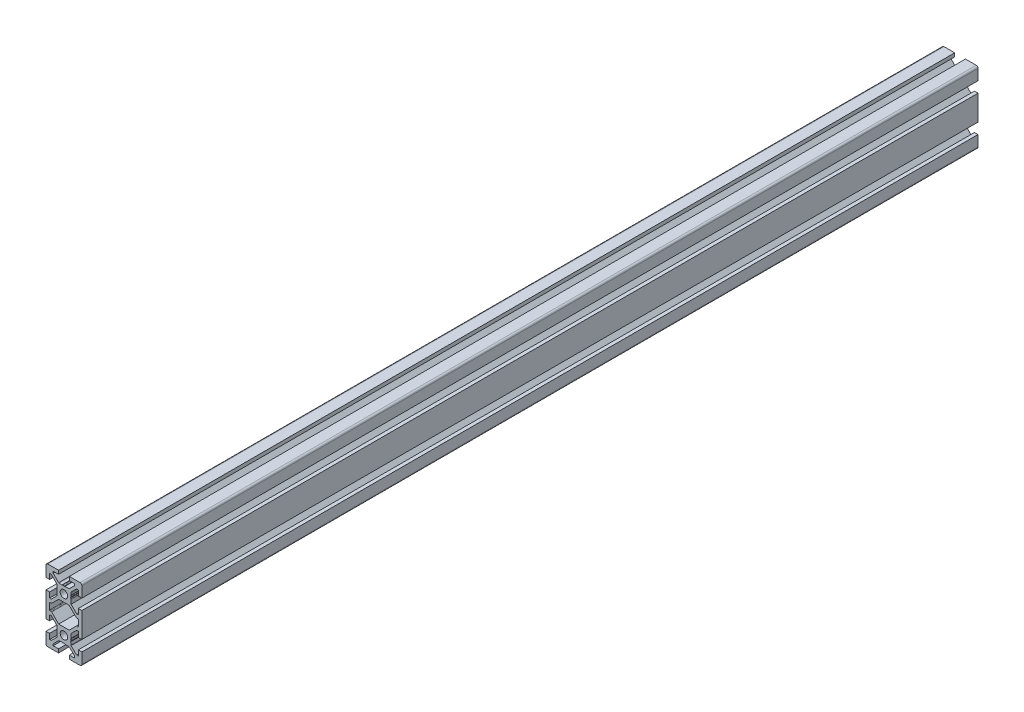
from build123d import *

# Parameters (mm, degrees)
SKETCH1_R           = 2.1
BOSS_EXTRUDE1_DEPTH = 500


with BuildPart() as part:
    # Sketch1 → Boss-Extrude1 (new body)
    with BuildSketch(Plane(origin=(0, 0, -600), x_dir=(-1, 0, 0), z_dir=(0, 0, -1))):
        with BuildLine():
            Line((10, -7), (10, 7))
            Line((10, 7), (8, 7))
            Line((8, 7), (8, 4))
            Line((8, 4), (7.060660172, 4))
            Line((7.060660172, 4), (4, 7.060660172))
            Line((4, 7.060660172), (4, 7.5))
            Line((4, 7.5), (3.750976592, 8.781114371))
            Line((3.750976592, 8.781114371), (3.933012702, 9.096410162))
            ThreePointArc((3.933012702, 9.096410162), (4, 9.346410162), (3.933012702, 9.596410162))
            Line((3.933012702, 9.596410162), (3.7, 10))
            Line((3.7, 10), (3.933012702, 10.403589838))
            ThreePointArc((3.933012702, 10.403589838), (3.982962913, 10.524180316), (4, 10.653589838))
            Line((4, 10.653589838), (4, 12.939339828))
            Line((4, 12.939339828), (7.060660172, 16))
            Line((7.060660172, 16), (8, 16))
            Line((8, 16), (8, 13))
            Line((8, 13), (10, 13))
            Line((10, 13), (10, 19))
            ThreePointArc((10, 19), (9.707106781, 19.707106781), (9, 20))
            Line((9, 20), (3, 20))
            Line((3, 20), (3, 18))
            Line((3, 18), (6, 18))
            Line((6, 18), (6, 17.060660172))
            Line((6, 17.060660172), (2.939339828, 14))
            Line((2.939339828, 14), (2.5, 14))
            Line((2.5, 14), (1.218885629, 13.750976592))
            Line((1.218885629, 13.750976592), (0.903589838, 13.933012702))
            ThreePointArc((0.903589838, 13.933012702), (0.653589838, 14), (0.403589838, 13.933012702))
            Line((0.403589838, 13.933012702), (0, 13.7))
            Line((0, 13.7), (-0.403589838, 13.933012702))
            ThreePointArc((-0.403589838, 13.933012702), (-0.524180316, 13.982962913), (-0.653589838, 14))
            Line((-0.653589838, 14), (-2.939339828, 14))
            Line((-2.939339828, 14), (-6, 17.060660172))
            Line((-6, 17.060660172), (-6, 18))
            Line((-6, 18), (-3, 18))
            Line((-3, 18), (-3, 20))
            Line((-3, 20), (-9, 20))
            ThreePointArc((-9, 20), (-9.707106781, 19.707106781), (-10, 19))
            Line((-10, 19), (-10, 13))
            Line((-10, 13), (-8, 13))
            Line((-8, 13), (-8, 16))
            Line((-8, 16), (-7.060660172, 16))
            Line((-7.060660172, 16), (-4, 12.939339828))
            Line((-4, 12.939339828), (-4, 12.5))
            Line((-4, 12.5), (-3.750976592, 11.218885629))
            Line((-3.750976592, 11.218885629), (-3.933012702, 10.903589838))
            ThreePointArc((-3.933012702, 10.903589838), (-4, 10.653589838), (-3.933012702, 10.403589838))
            Line((-3.933012702, 10.403589838), (-3.7, 10))
            Line((-3.7, 10), (-3.933012702, 9.596410162))
            ThreePointArc((-3.933012702, 9.596410162), (-3.982962913, 9.475819684), (-4, 9.346410162))
            Line((-4, 9.346410162), (-4, 7.060660172))
            Line((-4, 7.060660172), (-7.060660172, 4))
            Line((-7.060660172, 4), (-8, 4))
            Line((-8, 4), (-8, 7))
            Line((-8, 7), (-10, 7))
            Line((-10, 7), (-10, -7))
            Line((-10, -7), (-8, -7))
            Line((-8, -7), (-8, -4))
            Line((-8, -4), (-7.060660172, -4))
            Line((-7.060660172, -4), (-4, -7.060660172))
            Line((-4, -7.060660172), (-4, -9.346410162))
            ThreePointArc((-4, -9.346410162), (-3.982962913, -9.475819684), (-3.933012702, -9.596410162))
            Line((-3.933012702, -9.596410162), (-3.7, -10))
            Line((-3.7, -10), (-3.933012702, -10.403589838))
            ThreePointArc((-3.933012702, -10.403589838), (-4, -10.653589838), (-3.933012702, -10.903589838))
            Line((-3.933012702, -10.903589838), (-3.750976592, -11.218885629))
            Line((-3.750976592, -11.218885629), (-4, -12.5))
            Line((-4, -12.5), (-4, -12.939339828))
            Line((-4, -12.939339828), (-7.060660172, -16))
            Line((-7.060660172, -16), (-8, -16))
            Line((-8, -16), (-8, -13))
            Line((-8, -13), (-10, -13))
            Line((-10, -13), (-10, -19))
            ThreePointArc((-10, -19), (-9.707106781, -19.707106781), (-9, -20))
            Line((-9, -20), (-3, -20))
            Line((-3, -20), (-3, -18))
            Line((-3, -18), (-6, -18))
            Line((-6, -18), (-6, -17.060660172))
            Line((-6, -17.060660172), (-2.939339828, -14))
            Line((-2.939339828, -14), (-0.653589838, -14))
            ThreePointArc((-0.653589838, -14), (-0.524180316, -13.982962913), (-0.403589838, -13.933012702))
            Line((-0.403589838, -13.933012702), (0, -13.7))
            Line((0, -13.7), (0.403589839, -13.933012702))
            ThreePointArc((0.403589839, -13.933012702), (0.653589839, -14), (0.903589838, -13.933012702))
            Line((0.903589838, -13.933012702), (1.218885629, -13.750976592))
            Line((1.218885629, -13.750976592), (2.5, -14))
            Line((2.5, -14), (2.939339828, -14))
            Line((2.939339828, -14), (6, -17.060660172))
            Line((6, -17.060660172), (6, -18))
            Line((6, -18), (3, -18))
            Line((3, -18), (3, -20))
            Line((3, -20), (9, -20))
            ThreePointArc((9, -20), (9.707106781, -19.707106781), (10, -19))
            Line((10, -19), (10, -13))
            Line((10, -13), (8, -13))
            Line((8, -13), (8, -16))
            Line((8, -16), (7.060660172, -16))
            Line((7.060660172, -16), (4, -12.939339828))
            Line((4, -12.939339828), (4, -10.653589838))
            ThreePointArc((4, -10.653589838), (3.982962913, -10.524180316), (3.933012702, -10.403589838))
            Line((3.933012702, -10.403589838), (3.7, -10))
            Line((3.7, -10), (3.933012702, -9.596410162))
            ThreePointArc((3.933012702, -9.596410162), (4, -9.346410162), (3.933012702, -9.096410162))
            Line((3.933012702, -9.096410162), (3.750976592, -8.781114371))
            Line((3.750976592, -8.781114371), (4, -7.5))
            Line((4, -7.5), (4, -7.060660172))
            Line((4, -7.060660172), (7.060660172, -4))
            Line((7.060660172, -4), (8, -4))
            Line((8, -4), (8, -7))
            Line((8, -7), (10, -7))
        make_face()
        with Locations((0, -10)):
            Circle(SKETCH1_R, mode=Mode.SUBTRACT)
        with Locations((0, 10)):
            Circle(SKETCH1_R, mode=Mode.SUBTRACT)
        with BuildLine():
            Line((8, 1.7), (8, -1.7))
            ThreePointArc((8, -1.7), (7.912132034, -1.912132034), (7.7, -2))
            Line((7.7, -2), (7.063603897, -2))
            ThreePointArc((7.063603897, -2), (6.948798867, -2.02283614), (6.851471863, -2.087867966))
            Line((6.851471863, -2.087867966), (2.939339828, -6))
            Line((2.939339828, -6), (-2.939339828, -6))
            Line((-2.939339828, -6), (-6.851471863, -2.087867966))
            ThreePointArc((-6.851471863, -2.087867966), (-6.948798867, -2.02283614), (-7.063603897, -2))
            Line((-7.063603897, -2), (-7.7, -2))
            ThreePointArc((-7.7, -2), (-7.912132034, -1.912132034), (-8, -1.7))
            Line((-8, -1.7), (-8, 1.7))
            ThreePointArc((-8, 1.7), (-7.912132034, 1.912132034), (-7.7, 2))
            Line((-7.7, 2), (-7.063603897, 2))
            ThreePointArc((-7.063603897, 2), (-6.948798867, 2.02283614), (-6.851471863, 2.087867966))
            Line((-6.851471863, 2.087867966), (-2.939339828, 6))
            Line((-2.939339828, 6), (2.939339828, 6))
            Line((2.939339828, 6), (6.851471863, 2.087867966))
            ThreePointArc((6.851471863, 2.087867966), (6.948798867, 2.02283614), (7.063603897, 2))
            Line((7.063603897, 2), (7.7, 2))
            ThreePointArc((7.7, 2), (7.912132034, 1.912132034), (8, 1.7))
        make_face(mode=Mode.SUBTRACT)
    extrude(amount=-BOSS_EXTRUDE1_DEPTH)


solid = part.part
